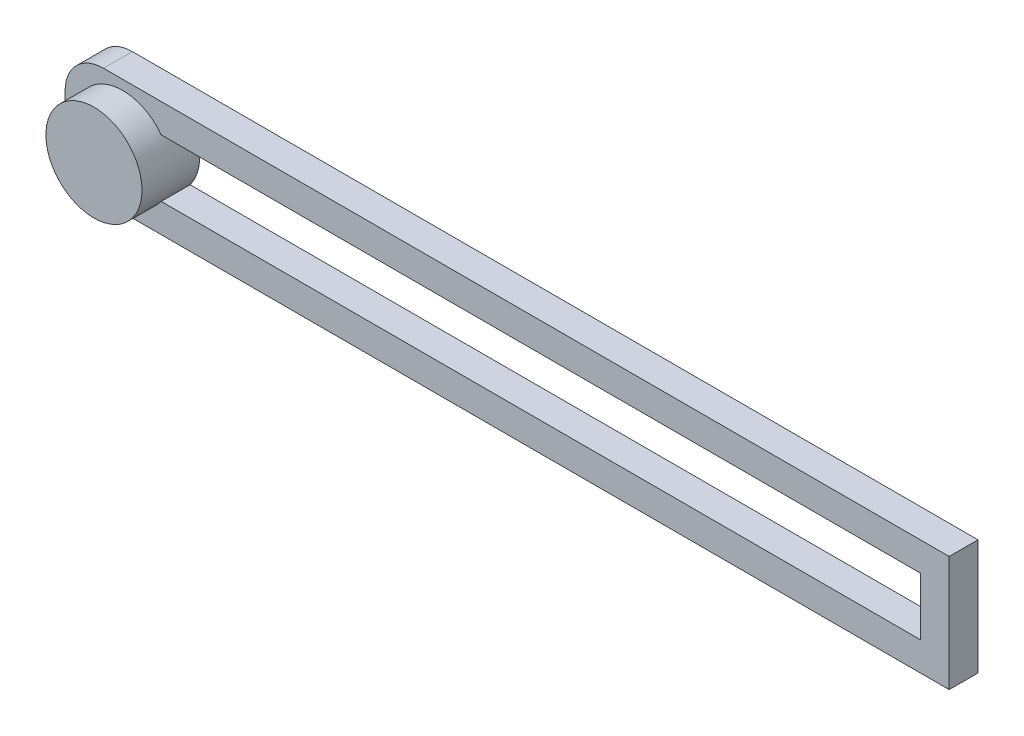
from build123d import *

# Parameters (mm, degrees)
SKETCH1_W                = 92
SKETCH1_H                = 12
BOSS_EXTRUDE1_DEPTH      = 3
FILLET1_R                = 4
CUT_EXTRUDE1_DEPTH       = 3
SKETCH3_R                = 5
BOSS_EXTRUDE2_DEPTH      = 3
BOSS_EXTRUDE2_DEPTH_BACK = 3


with BuildPart() as part:
    # Sketch1 → Boss-Extrude1 (new body)
    with BuildSketch(Plane.XY):
        Rectangle(SKETCH1_W, SKETCH1_H)
    extrude(amount=BOSS_EXTRUDE1_DEPTH)

    # Fillet1
    fillet1_edges = [part.edges().sort_by_distance(p)[0] for p in [
        (-46, -6, 1.5),
        (-46, 6, 1.5),
    ]]
    fillet(fillet1_edges, radius=FILLET1_R)

    # Sketch2 → Cut-Extrude1 (cut)
    with BuildSketch(Plane.XY.offset(3)):
        with BuildLine():
            Line((-43, 2), (-43, -2))
            ThreePointArc((-43, -2), (-42.707106781, -2.707106781), (-42, -3))
            Line((-42, -3), (43, -3))
            Line((43, -3), (43, 3))
            Line((43, 3), (-42, 3))
            ThreePointArc((-42, 3), (-42.707106781, 2.707106781), (-43, 2))
        make_face()
    extrude(amount=-CUT_EXTRUDE1_DEPTH, mode=Mode.SUBTRACT)

    # Sketch3 → Boss-Extrude2 (add, two sides)
    with BuildSketch(Plane.XY.offset(3)) as boss_extrude2_sk:
        with Locations((-40, 0)):
            Circle(SKETCH3_R)
    extrude(amount=BOSS_EXTRUDE2_DEPTH)
    extrude(boss_extrude2_sk.sketch, amount=-BOSS_EXTRUDE2_DEPTH_BACK)


solid = part.part
